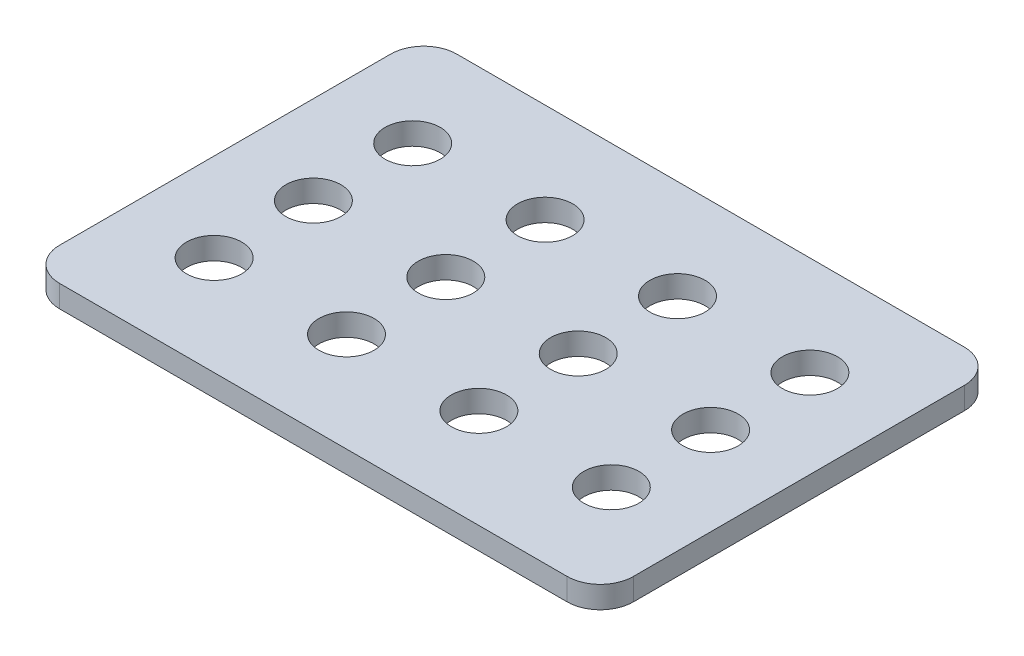
from build123d import *

# Parameters (mm, degrees)
SKETCH1_R           = 12.5
BOSS_EXTRUDE1_DEPTH = 10


with BuildPart() as part:
    # Sketch1 → Boss-Extrude1 (new body)
    with BuildSketch(Plane(origin=(0, 0, 0), x_dir=(1, 0, 0), z_dir=(0, 1, 0))):
        with BuildLine():
            Line((-115, 90), (115, 90))
            ThreePointArc((115, 90), (125.606601718, 85.606601718), (130, 75))
            Line((130, 75), (130, -75))
            ThreePointArc((130, -75), (125.606601718, -85.606601718), (115, -90))
            Line((115, -90), (-115, -90))
            ThreePointArc((-115, -90), (-125.606601718, -85.606601718), (-130, -75))
            Line((-130, -75), (-130, 75))
            ThreePointArc((-130, 75), (-125.606601718, 85.606601718), (-115, 90))
        make_face()
        with Locations((-90, -45)):
            Circle(SKETCH1_R, mode=Mode.SUBTRACT)
        with Locations((-30, -45)):
            Circle(SKETCH1_R, mode=Mode.SUBTRACT)
        with Locations((30, -45)):
            Circle(SKETCH1_R, mode=Mode.SUBTRACT)
        with Locations((90, -45)):
            Circle(SKETCH1_R, mode=Mode.SUBTRACT)
        with Locations((-30, 0)):
            Circle(SKETCH1_R, mode=Mode.SUBTRACT)
        with Locations((30, 0)):
            Circle(SKETCH1_R, mode=Mode.SUBTRACT)
        with Locations((90, 0)):
            Circle(SKETCH1_R, mode=Mode.SUBTRACT)
        with Locations((-30, 45)):
            Circle(SKETCH1_R, mode=Mode.SUBTRACT)
        with Locations((30, 45)):
            Circle(SKETCH1_R, mode=Mode.SUBTRACT)
        with Locations((90, 45)):
            Circle(SKETCH1_R, mode=Mode.SUBTRACT)
        with Locations((-90, 0)):
            Circle(SKETCH1_R, mode=Mode.SUBTRACT)
        with Locations((-90, 45)):
            Circle(SKETCH1_R, mode=Mode.SUBTRACT)
    extrude(amount=BOSS_EXTRUDE1_DEPTH)


solid = part.part
